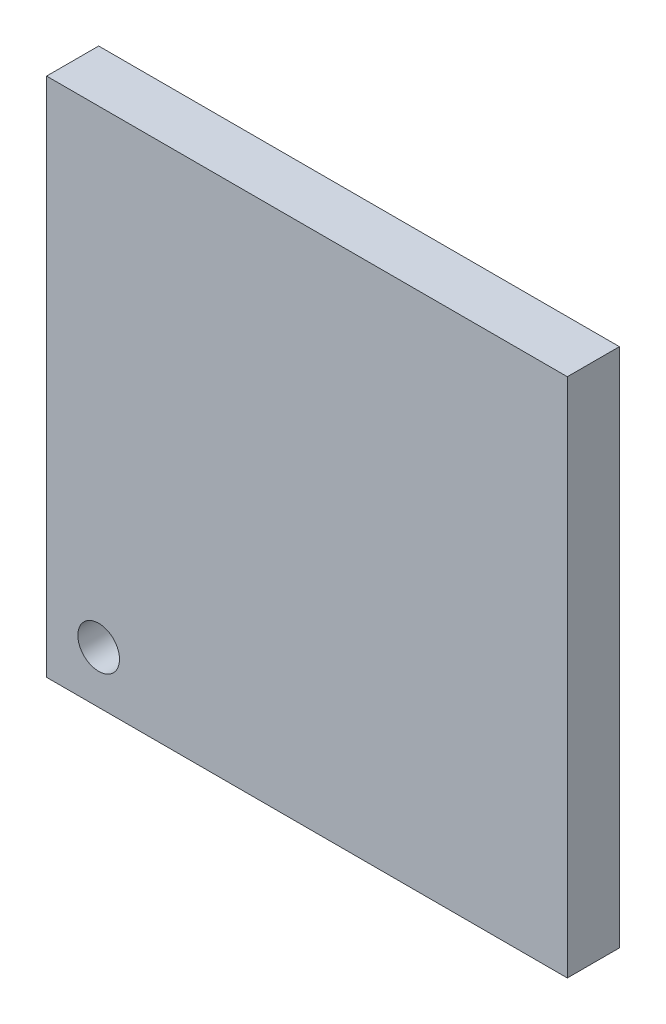
from build123d import *

# Parameters (mm, degrees)
SKICA1_W                 = 100
SKICA1_H                 = 100
P_IDAT_VYSUNUT_M1_DEPTH  = 10
ODEBRAT_VYSUNUT_M1_REACH = 12
SKICA3_R                 = 4


with BuildPart() as part:
    # Skica1 → Přidat vysunutím1 (new body)
    with BuildSketch(Plane.XY):
        Rectangle(SKICA1_W, SKICA1_H)
    extrude(amount=P_IDAT_VYSUNUT_M1_DEPTH)

    # Skica3 → Odebrat vysunutím1 (cut, up to next)
    with BuildSketch(Plane.XY.offset(10), mode=Mode.PRIVATE) as odebrat_vysunut_m1_sk1:
        with Locations((-40, -40)):
            Circle(SKICA3_R)
    odebrat_vysunut_m1_tool1 = extrude(odebrat_vysunut_m1_sk1.sketch, amount=-ODEBRAT_VYSUNUT_M1_REACH, mode=Mode.PRIVATE) & part.part
    add(odebrat_vysunut_m1_tool1.solids().sort_by_distance((-40, -40, 10))[0], mode=Mode.SUBTRACT)


solid = part.part
